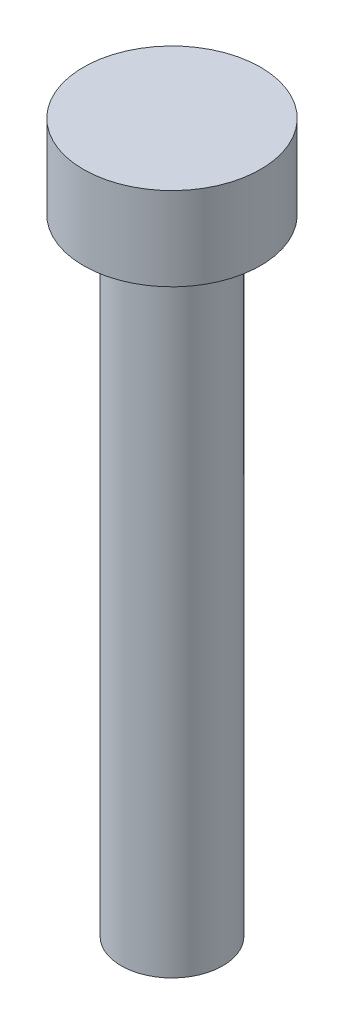
from build123d import *

# Parameters (mm, degrees)
SKETCH1_R           = 4.25
BOSS_EXTRUDE1_DEPTH = 4
SKETCH2_R           = 2.44
BOSS_EXTRUDE2_DEPTH = 30


with BuildPart() as part:
    # Sketch1 → Boss-Extrude1 (new body)
    with BuildSketch(Plane(origin=(0, 0, 0), x_dir=(1, 0, 0), z_dir=(0, 1, 0))):
        Circle(SKETCH1_R)
    extrude(amount=BOSS_EXTRUDE1_DEPTH)

    # Sketch2 → Boss-Extrude2 (add)
    with BuildSketch(Plane.XZ):
        Circle(SKETCH2_R)
    extrude(amount=BOSS_EXTRUDE2_DEPTH)


solid = part.part
